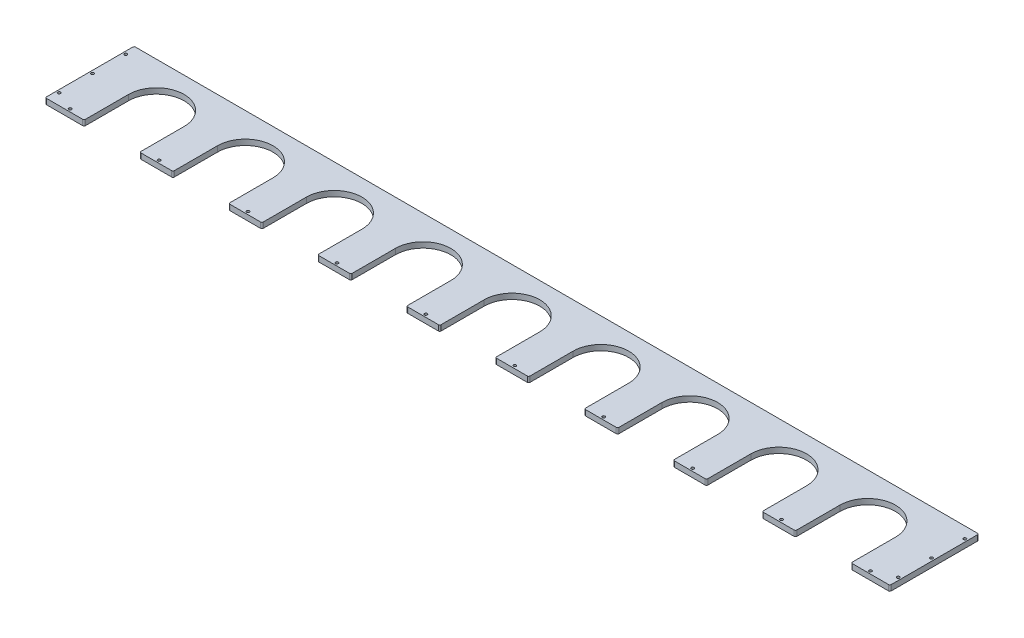
from build123d import *

# Parameters (mm, degrees)
SKETCH1_W                   = 1930.4
SKETCH1_H                   = 203.2
BOSS_EXTRUDE1_DEPTH         = 12.7
CUT_EXTRUDE1_DEPTH          = 13.7
FILLET1_R                   = 3.175
F_1_4_0_25_DIAMETER_HOLE1_D = 6.35


with BuildPart() as part:
    # Sketch1 → Boss-Extrude1 (new body)
    with BuildSketch(Plane(origin=(0, 0, 0), x_dir=(1, 0, 0), z_dir=(0, 1, 0))):
        Rectangle(SKETCH1_W, SKETCH1_H)
    extrude(amount=BOSS_EXTRUDE1_DEPTH)

    # Sketch2 → Cut-Extrude1 (cut, through all)
    with BuildSketch(Plane(origin=(0, 12.7, 0), x_dir=(1, 0, 0), z_dir=(0, 1, 0))):
        with BuildLine():
            Line((-876.3, 0), (-876.3, -101.6))
            Line((-876.3, -101.6), (-749.3, -101.6))
            Line((-749.3, -101.6), (-749.3, 0))
            ThreePointArc((-749.3, 0), (-812.8, 63.5), (-876.3, 0))
        make_face()
        with BuildLine():
            Line((-673.1, 0), (-673.1, -101.6))
            Line((-673.1, -101.6), (-546.1, -101.6))
            Line((-546.1, -101.6), (-546.1, 0))
            ThreePointArc((-546.1, 0), (-609.6, 63.5), (-673.1, 0))
        make_face()
        with BuildLine():
            Line((-469.9, 0), (-469.9, -101.6))
            Line((-469.9, -101.6), (-342.9, -101.6))
            Line((-342.9, -101.6), (-342.9, 0))
            ThreePointArc((-342.9, 0), (-406.4, 63.5), (-469.9, 0))
        make_face()
        with BuildLine():
            Line((-266.7, 0), (-266.7, -101.6))
            Line((-266.7, -101.6), (-139.7, -101.6))
            Line((-139.7, -101.6), (-139.7, 0))
            ThreePointArc((-139.7, 0), (-203.2, 63.5), (-266.7, 0))
        make_face()
        with BuildLine():
            Line((-63.5, 0), (-63.5, -101.6))
            Line((-63.5, -101.6), (63.5, -101.6))
            Line((63.5, -101.6), (63.5, 0))
            ThreePointArc((63.5, 0), (0, 63.5), (-63.5, 0))
        make_face()
        with BuildLine():
            Line((139.7, 0), (139.7, -101.6))
            Line((139.7, -101.6), (266.7, -101.6))
            Line((266.7, -101.6), (266.7, 0))
            ThreePointArc((266.7, 0), (203.2, 63.5), (139.7, 0))
        make_face()
        with BuildLine():
            Line((342.9, 0), (342.9, -101.6))
            Line((342.9, -101.6), (469.9, -101.6))
            Line((469.9, -101.6), (469.9, 0))
            ThreePointArc((469.9, 0), (406.4, 63.5), (342.9, 0))
        make_face()
        with BuildLine():
            Line((546.1, 0), (546.1, -101.6))
            Line((546.1, -101.6), (673.1, -101.6))
            Line((673.1, -101.6), (673.1, 0))
            ThreePointArc((673.1, 0), (609.6, 63.5), (546.1, 0))
        make_face()
        with BuildLine():
            Line((749.3, 0), (749.3, -101.6))
            Line((749.3, -101.6), (876.3, -101.6))
            Line((876.3, -101.6), (876.3, 0))
            ThreePointArc((876.3, 0), (812.8, 63.5), (749.3, 0))
        make_face()
    extrude(amount=-CUT_EXTRUDE1_DEPTH, mode=Mode.SUBTRACT)

    # Fillet1
    fillet1_edges = [part.edges().sort_by_distance(p)[0] for p in [
        (546.1, 6.35, 101.6),
        (876.3, 6.35, 101.6),
        (749.3, 6.35, 101.6),
        (-749.3, 6.35, 101.6),
        (-876.3, 6.35, 101.6),
        (-546.1, 6.35, 101.6),
        (-673.1, 6.35, 101.6),
        (-342.9, 6.35, 101.6),
        (-469.9, 6.35, 101.6),
        (-139.7, 6.35, 101.6),
        (-266.7, 6.35, 101.6),
        (-965.2, 6.35, 101.6),
        (-965.2, 6.35, -101.6),
        (965.2, 6.35, -101.6),
        (965.2, 6.35, 101.6),
        (63.5, 6.35, 101.6),
        (-63.5, 6.35, 101.6),
        (266.7, 6.35, 101.6),
        (139.7, 6.35, 101.6),
        (469.9, 6.35, 101.6),
        (342.9, 6.35, 101.6),
        (673.1, 6.35, 101.6),
    ]]
    fillet(fillet1_edges, radius=FILLET1_R)

    # 1/4 (0.25) Diameter Hole1 (through all)
    with Locations(Plane(origin=(0, 12.7, 0), x_dir=(1, 0, 0), z_dir=(0, 1, 0))):
        with Locations((-958.85, 76.2), (-958.85, 0), (-958.85, -76.2), (958.85, -76.2), (958.85, 0), (958.85, 76.2), (-914.4, -95.25), (-711.2, -95.25), (-508, -95.25), (-304.8, -95.25), (-101.6, -95.25), (101.6, -95.25), (304.8, -95.25), (508, -95.25), (711.2, -95.25), (914.4, -95.25)):
            Hole(F_1_4_0_25_DIAMETER_HOLE1_D / 2)


solid = part.part
